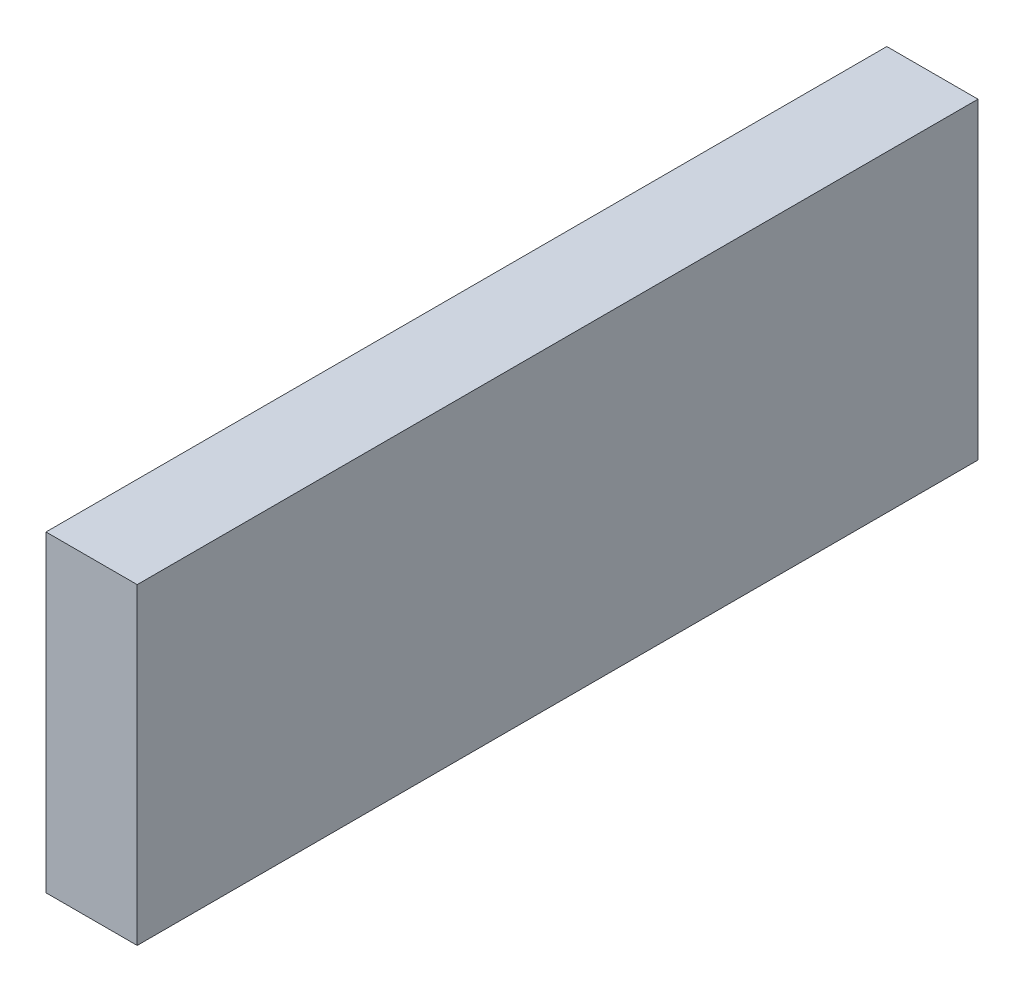
from build123d import *

# Parameters (mm, degrees)
CROQUIS1_W              = 46.10048772
CROQUIS1_H              = 17.134694551
SALIENTE_EXTRUIR1_DEPTH = 5
VACIADO2_T              = -0.5


with BuildPart() as part:
    # Croquis1 → Saliente-Extruir1 (new body)
    with BuildSketch(Plane(origin=(0, 0, 0), x_dir=(0, 0, -1), z_dir=(1, 0, 0))):
        with Locations((23.05024386, 8.567347276)):
            Rectangle(CROQUIS1_W, CROQUIS1_H)
    extrude(amount=SALIENTE_EXTRUIR1_DEPTH)

    # Vaciado2
    vaciado2_openings = [part.faces().sort_by_distance(p)[0] for p in [
        (2.5, 8.567347275, -46.10048772),
    ]]
    offset(amount=VACIADO2_T, openings=vaciado2_openings, kind=Kind.INTERSECTION)


solid = part.part
